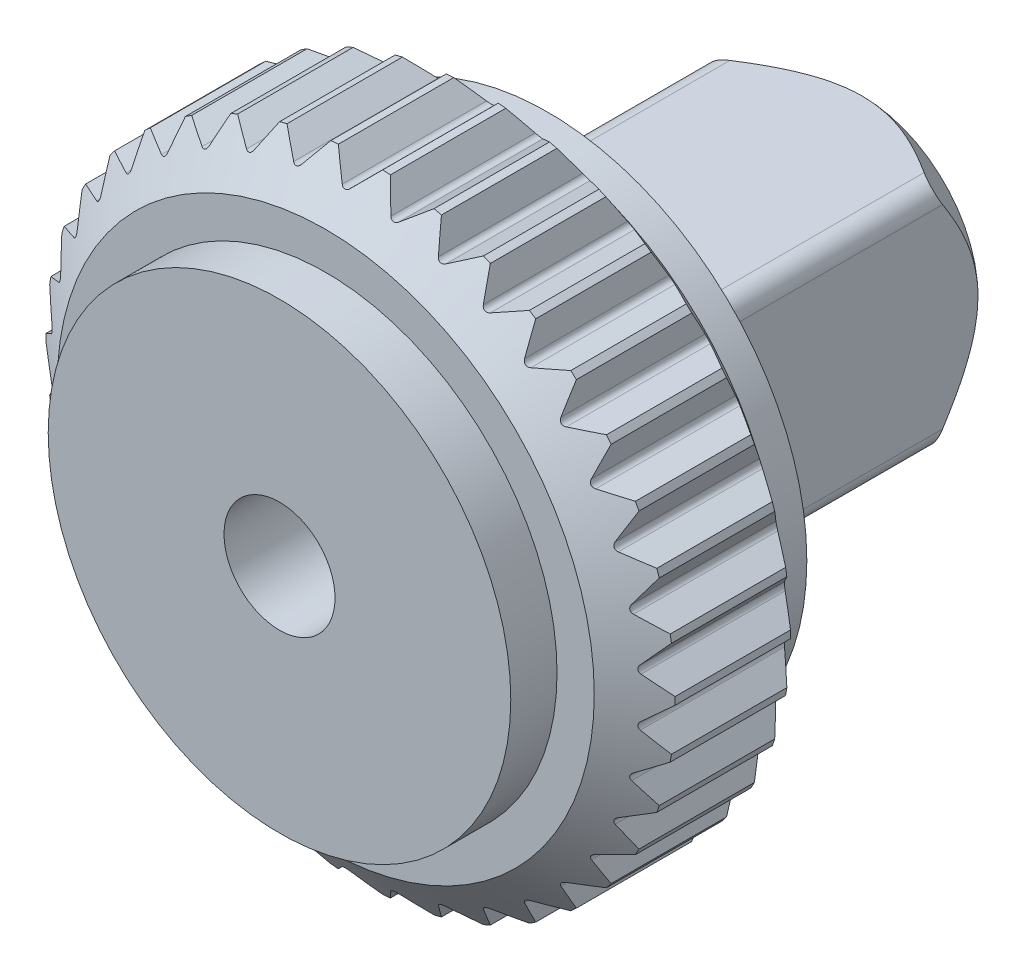
from build123d import *

# Parameters (mm, degrees)
DODANIE_WYCI_GNI_CIE1_DEPTH = 10
SZKIC3_R                    = 12.5
DODANIE_WYCI_GNI_CIE2_DEPTH = 2.5
SZKIC4_R                    = 14
DODANIE_WYCI_GNI_CIE3_DEPTH = 2
DODANIE_WYCI_GNI_CIE4_DEPTH = 17
ZAOKR_GLENIE1_R             = 1
SZKIC6_R                    = 3
WYTNIJ_WYCI_GNI_CIE1_DEPTH  = 32.5
SZKIC7_OUTSIDE_W            = 81.486
SZKIC7_OUTSIDE_H            = 81.402
SZKIC7_OUTSIDE_R            = 6.25
WYTNIJ_WYCI_GNI_CIE2_DEPTH  = 17
WYTNIJ_WYCI_GNI_CIE2_TAPER  = 45


with BuildPart() as part:
    # Szkic1 → Dodanie-wyciągnięcie1 (new body)
    with BuildSketch(Plane.XY):
        with BuildLine():
            Line((0.212132034, 15.969726203), (1.2, 16.957594169))
            ThreePointArc((1.2, 16.957594169), (1.403848873, 16.941936381), (1.6074947, 16.923828195))
            Line((1.6074947, 16.923828195), (2.419291711, 15.786835738))
            ThreePointArc((2.419291711, 15.786835738), (2.61406795, 15.665250392), (2.837769371, 15.717004168))
            Line((2.837769371, 15.717004168), (3.974761828, 16.528801179))
            ThreePointArc((3.974761828, 16.528801179), (4.173253281, 16.479804521), (4.371141136, 16.428424306))
            Line((4.371141136, 16.428424306), (4.984723486, 15.173321547))
            ThreePointArc((4.984723486, 15.173321547), (5.15683094, 15.021335351), (5.385999757, 15.035563229))
            Line((5.385999757, 15.035563229), (6.641102516, 15.64914558))
            ThreePointArc((6.641102516, 15.64914558), (6.828822219, 15.568146553), (7.015554235, 15.484895827))
            Line((7.015554235, 15.484895827), (7.414184998, 14.145918699))
            ThreePointArc((7.414184998, 14.145918699), (7.558929025, 13.96767744), (7.78731411, 13.943991321))
            Line((7.78731411, 13.943991321), (9.126291238, 14.342622084))
            ThreePointArc((9.126291238, 14.342622084), (9.298118688, 14.23183013), (9.468601304, 14.118979756))
            Line((9.468601304, 14.118979756), (9.641406871, 12.732652063))
            ThreePointArc((9.641406871, 12.732652063), (9.754839231, 12.5330177), (9.976210834, 12.472063679))
            Line((9.976210834, 12.472063679), (11.362538526, 12.644869245))
            ThreePointArc((11.362538526, 12.644869245), (11.513786718, 12.507306481), (11.663369612, 12.367934723))
            Line((11.663369612, 12.367934723), (11.605636297, 10.972071871))
            ThreePointArc((11.605636297, 10.972071871), (11.684662851, 10.756489908), (11.892982532, 10.659930652))
            Line((11.892982532, 10.659930652), (13.288845384, 10.602197337))
            ThreePointArc((13.288845384, 10.602197337), (13.41538866, 10.441616116), (13.539991601, 10.279524671))
            Line((13.539991601, 10.279524671), (13.253294219, 8.912202161))
            ThreePointArc((13.253294219, 8.912202161), (13.295759329, 8.686553111), (13.48534467, 8.557022505))
            Line((13.48534467, 8.557022505), (14.85266718, 8.270325123))
            ThreePointArc((14.85266718, 8.270325123), (14.951053771, 8.091105682), (15.047277915, 7.910715983))
            Line((15.047277915, 7.910715983), (14.539436823, 6.609230808))
            ThreePointArc((14.539436823, 6.609230808), (14.544182152, 6.379669789), (14.709861759, 6.22070109))
            Line((14.709861759, 6.22070109), (16.011346934, 5.712859999))
            ThreePointArc((16.011346934, 5.712859999), (16.078893109, 5.519890976), (16.144113713, 5.326123584))
            Line((16.144113713, 5.326123584), (15.428981493, 4.125976867))
            ThreePointArc((15.428981493, 4.125976867), (15.395877599, 3.898765706), (15.533132164, 3.714695166))
            Line((15.533132164, 3.714695166), (16.733278882, 2.999562946))
            ThreePointArc((16.733278882, 2.999562946), (16.768142158, 2.798108035), (16.800580173, 2.596248419))
            Line((16.800580173, 2.596248419), (15.897663767, 1.530177033))
            ThreePointArc((15.897663767, 1.530177033), (15.82761364, 1.311513458), (15.932699216, 1.107362041))
            Line((15.932699216, 1.107362041), (16.998770602, 0.204445636))
            ThreePointArc((16.998770602, 0.204445636), (17, 0), (16.998770602, -0.204445636))
            Line((16.998770602, -0.204445636), (15.932699216, -1.107362041))
            ThreePointArc((15.932699216, -1.107362041), (15.82761364, -1.311513458), (15.897663767, -1.530177033))
            Line((15.897663767, -1.530177033), (16.800580173, -2.596248419))
            ThreePointArc((16.800580173, -2.596248419), (16.768142158, -2.798108035), (16.733278882, -2.999562946))
            Line((16.733278882, -2.999562946), (15.533132164, -3.714695166))
            ThreePointArc((15.533132164, -3.714695166), (15.395877599, -3.898765706), (15.428981493, -4.125976867))
            Line((15.428981493, -4.125976867), (16.144113713, -5.326123584))
            ThreePointArc((16.144113713, -5.326123584), (16.078893109, -5.519890976), (16.011346934, -5.712859999))
            Line((16.011346934, -5.712859999), (14.709861759, -6.22070109))
            ThreePointArc((14.709861759, -6.22070109), (14.544182152, -6.379669789), (14.539436823, -6.609230808))
            Line((14.539436823, -6.609230808), (15.047277915, -7.910715983))
            ThreePointArc((15.047277915, -7.910715983), (14.951053771, -8.091105682), (14.85266718, -8.270325123))
            Line((14.85266718, -8.270325123), (13.48534467, -8.557022505))
            ThreePointArc((13.48534467, -8.557022505), (13.295759329, -8.686553111), (13.253294219, -8.912202161))
            Line((13.253294219, -8.912202161), (13.539991601, -10.279524671))
            ThreePointArc((13.539991601, -10.279524671), (13.41538866, -10.441616116), (13.288845384, -10.602197337))
            Line((13.288845384, -10.602197337), (11.892982532, -10.659930652))
            ThreePointArc((11.892982532, -10.659930652), (11.684662851, -10.756489908), (11.605636297, -10.972071871))
            Line((11.605636297, -10.972071871), (11.663369612, -12.367934723))
            ThreePointArc((11.663369612, -12.367934723), (11.513786718, -12.507306481), (11.362538526, -12.644869245))
            Line((11.362538526, -12.644869245), (9.976210834, -12.472063679))
            ThreePointArc((9.976210834, -12.472063679), (9.754839231, -12.5330177), (9.641406871, -12.732652063))
            Line((9.641406871, -12.732652063), (9.468601304, -14.118979756))
            ThreePointArc((9.468601304, -14.118979756), (9.298118688, -14.23183013), (9.126291238, -14.342622084))
            Line((9.126291238, -14.342622084), (7.78731411, -13.943991321))
            ThreePointArc((7.78731411, -13.943991321), (7.558929025, -13.96767744), (7.414184998, -14.145918699))
            Line((7.414184998, -14.145918699), (7.015554235, -15.484895827))
            ThreePointArc((7.015554235, -15.484895827), (6.828822219, -15.568146553), (6.641102516, -15.64914558))
            Line((6.641102516, -15.64914558), (5.385999757, -15.035563229))
            ThreePointArc((5.385999757, -15.035563229), (5.15683094, -15.021335351), (4.984723486, -15.173321547))
            Line((4.984723486, -15.173321547), (4.371141136, -16.428424306))
            ThreePointArc((4.371141136, -16.428424306), (4.173253281, -16.479804521), (3.974761828, -16.528801179))
            Line((3.974761828, -16.528801179), (2.837769371, -15.717004168))
            ThreePointArc((2.837769371, -15.717004168), (2.61406795, -15.665250392), (2.419291711, -15.786835738))
            Line((2.419291711, -15.786835738), (1.6074947, -16.923828195))
            ThreePointArc((1.6074947, -16.923828195), (1.403848873, -16.941936381), (1.2, -16.957594169))
            Line((1.2, -16.957594169), (0.212132034, -15.969726203))
            ThreePointArc((0.212132034, -15.969726203), (0, -15.881858238), (-0.212132034, -15.969726203))
            Line((-0.212132034, -15.969726203), (-1.2, -16.957594169))
            ThreePointArc((-1.2, -16.957594169), (-1.403848873, -16.941936381), (-1.6074947, -16.923828195))
            Line((-1.6074947, -16.923828195), (-2.419291711, -15.786835738))
            ThreePointArc((-2.419291711, -15.786835738), (-2.61406795, -15.665250392), (-2.837769371, -15.717004168))
            Line((-2.837769371, -15.717004168), (-3.974761828, -16.528801179))
            ThreePointArc((-3.974761828, -16.528801179), (-4.173253281, -16.479804521), (-4.371141136, -16.428424306))
            Line((-4.371141136, -16.428424306), (-4.984723486, -15.173321547))
            ThreePointArc((-4.984723486, -15.173321547), (-5.15683094, -15.021335351), (-5.385999757, -15.035563229))
            Line((-5.385999757, -15.035563229), (-6.641102516, -15.64914558))
            ThreePointArc((-6.641102516, -15.64914558), (-6.828822219, -15.568146553), (-7.015554235, -15.484895827))
            Line((-7.015554235, -15.484895827), (-7.414184998, -14.145918699))
            ThreePointArc((-7.414184998, -14.145918699), (-7.558929025, -13.96767744), (-7.78731411, -13.943991321))
            Line((-7.78731411, -13.943991321), (-9.126291238, -14.342622084))
            ThreePointArc((-9.126291238, -14.342622084), (-9.298118688, -14.23183013), (-9.468601304, -14.118979756))
            Line((-9.468601304, -14.118979756), (-9.641406871, -12.732652063))
            ThreePointArc((-9.641406871, -12.732652063), (-9.754839231, -12.5330177), (-9.976210834, -12.472063679))
            Line((-9.976210834, -12.472063679), (-11.362538526, -12.644869245))
            ThreePointArc((-11.362538526, -12.644869245), (-11.513786718, -12.507306481), (-11.663369612, -12.367934723))
            Line((-11.663369612, -12.367934723), (-11.605636297, -10.972071871))
            ThreePointArc((-11.605636297, -10.972071871), (-11.684662851, -10.756489908), (-11.892982532, -10.659930652))
            Line((-11.892982532, -10.659930652), (-13.288845384, -10.602197337))
            ThreePointArc((-13.288845384, -10.602197337), (-13.41538866, -10.441616116), (-13.539991601, -10.279524671))
            Line((-13.539991601, -10.279524671), (-13.253294219, -8.912202161))
            ThreePointArc((-13.253294219, -8.912202161), (-13.295759329, -8.686553111), (-13.48534467, -8.557022505))
            Line((-13.48534467, -8.557022505), (-14.85266718, -8.270325123))
            ThreePointArc((-14.85266718, -8.270325123), (-14.951053771, -8.091105682), (-15.047277915, -7.910715983))
            Line((-15.047277915, -7.910715983), (-14.539436823, -6.609230808))
            ThreePointArc((-14.539436823, -6.609230808), (-14.544182152, -6.379669789), (-14.709861759, -6.22070109))
            Line((-14.709861759, -6.22070109), (-16.011346934, -5.712859999))
            ThreePointArc((-16.011346934, -5.712859999), (-16.078893109, -5.519890976), (-16.144113713, -5.326123584))
            Line((-16.144113713, -5.326123584), (-15.428981493, -4.125976867))
            ThreePointArc((-15.428981493, -4.125976867), (-15.395877599, -3.898765706), (-15.533132164, -3.714695166))
            Line((-15.533132164, -3.714695166), (-16.733278882, -2.999562946))
            ThreePointArc((-16.733278882, -2.999562946), (-16.768142158, -2.798108035), (-16.800580173, -2.596248419))
            Line((-16.800580173, -2.596248419), (-15.897663767, -1.530177033))
            ThreePointArc((-15.897663767, -1.530177033), (-15.82761364, -1.311513458), (-15.932699216, -1.107362041))
            Line((-15.932699216, -1.107362041), (-16.998770602, -0.204445636))
            ThreePointArc((-16.998770602, -0.204445636), (-17, 0), (-16.998770602, 0.204445636))
            Line((-16.998770602, 0.204445636), (-15.932699216, 1.107362041))
            ThreePointArc((-15.932699216, 1.107362041), (-15.82761364, 1.311513458), (-15.897663767, 1.530177033))
            Line((-15.897663767, 1.530177033), (-16.800580173, 2.596248419))
            ThreePointArc((-16.800580173, 2.596248419), (-16.768142158, 2.798108035), (-16.733278882, 2.999562946))
            Line((-16.733278882, 2.999562946), (-15.533132164, 3.714695166))
            ThreePointArc((-15.533132164, 3.714695166), (-15.395877599, 3.898765706), (-15.428981493, 4.125976867))
            Line((-15.428981493, 4.125976867), (-16.144113713, 5.326123584))
            ThreePointArc((-16.144113713, 5.326123584), (-16.078893109, 5.519890976), (-16.011346934, 5.712859999))
            Line((-16.011346934, 5.712859999), (-14.709861759, 6.22070109))
            ThreePointArc((-14.709861759, 6.22070109), (-14.544182152, 6.379669789), (-14.539436823, 6.609230808))
            Line((-14.539436823, 6.609230808), (-15.047277915, 7.910715983))
            ThreePointArc((-15.047277915, 7.910715983), (-14.951053771, 8.091105682), (-14.85266718, 8.270325123))
            Line((-14.85266718, 8.270325123), (-13.48534467, 8.557022505))
            ThreePointArc((-13.48534467, 8.557022505), (-13.295759329, 8.686553111), (-13.253294219, 8.912202161))
            Line((-13.253294219, 8.912202161), (-13.539991601, 10.279524671))
            ThreePointArc((-13.539991601, 10.279524671), (-13.41538866, 10.441616116), (-13.288845384, 10.602197337))
            Line((-13.288845384, 10.602197337), (-11.892982532, 10.659930652))
            ThreePointArc((-11.892982532, 10.659930652), (-11.684662851, 10.756489908), (-11.605636297, 10.972071871))
            Line((-11.605636297, 10.972071871), (-11.663369612, 12.367934723))
            ThreePointArc((-11.663369612, 12.367934723), (-11.513786718, 12.507306481), (-11.362538526, 12.644869245))
            Line((-11.362538526, 12.644869245), (-9.976210834, 12.472063679))
            ThreePointArc((-9.976210834, 12.472063679), (-9.754839231, 12.5330177), (-9.641406871, 12.732652063))
            Line((-9.641406871, 12.732652063), (-9.468601304, 14.118979756))
            ThreePointArc((-9.468601304, 14.118979756), (-9.298118688, 14.23183013), (-9.126291238, 14.342622084))
            Line((-9.126291238, 14.342622084), (-7.78731411, 13.943991321))
            ThreePointArc((-7.78731411, 13.943991321), (-7.558929025, 13.96767744), (-7.414184998, 14.145918699))
            Line((-7.414184998, 14.145918699), (-7.015554235, 15.484895827))
            ThreePointArc((-7.015554235, 15.484895827), (-6.828822219, 15.568146553), (-6.641102516, 15.64914558))
            Line((-6.641102516, 15.64914558), (-5.385999757, 15.035563229))
            ThreePointArc((-5.385999757, 15.035563229), (-5.15683094, 15.021335351), (-4.984723486, 15.173321547))
            Line((-4.984723486, 15.173321547), (-4.371141136, 16.428424306))
            ThreePointArc((-4.371141136, 16.428424306), (-4.173253281, 16.479804521), (-3.974761828, 16.528801179))
            Line((-3.974761828, 16.528801179), (-2.837769371, 15.717004168))
            ThreePointArc((-2.837769371, 15.717004168), (-2.61406795, 15.665250392), (-2.419291711, 15.786835738))
            Line((-2.419291711, 15.786835738), (-1.6074947, 16.923828195))
            ThreePointArc((-1.6074947, 16.923828195), (-1.403848873, 16.941936381), (-1.2, 16.957594169))
            Line((-1.2, 16.957594169), (-0.212132034, 15.969726203))
            ThreePointArc((-0.212132034, 15.969726203), (0, 15.881858238), (0.212132034, 15.969726203))
        make_face()
    extrude(amount=DODANIE_WYCI_GNI_CIE1_DEPTH)

    # Szkic2 → Wycięcie-obrót1 (revolve, cut)
    with BuildSketch(Plane(origin=(0, 0, 0), x_dir=(0, 0, -1), z_dir=(1, 0, 0))):
        Polygon((-10, 14.511390723), (-10, 17.157594169), (-8, 17.157594169), align=None)
        Polygon((-2, 17.157594169), (0, 14.511390723), (0, 17.157594169), align=None)
    revolve(axis=Axis((0, 0, 10), (0, 0, -1)), mode=Mode.SUBTRACT)

    # Szkic3 → Dodanie-wyciągnięcie2 (add)
    with BuildSketch(Plane.XY.offset(10)):
        Circle(SZKIC3_R)
    extrude(amount=DODANIE_WYCI_GNI_CIE2_DEPTH)

    # Szkic4 → Dodanie-wyciągnięcie3 (add)
    with BuildSketch(Plane(origin=(0, 0, 0), x_dir=(-1, 0, 0), z_dir=(0, 0, -1))):
        Circle(SZKIC4_R)
    extrude(amount=DODANIE_WYCI_GNI_CIE3_DEPTH)

    # Szkic5 → Dodanie-wyciągnięcie4 (add)
    with BuildSketch(Plane(origin=(0, 0, -2), x_dir=(-1, 0, 0), z_dir=(0, 0, -1))):
        with BuildLine():
            Line((-5.25, -6.25), (5.25, -6.25))
            ThreePointArc((5.25, -6.25), (5.957106781, -5.957106781), (6.25, -5.25))
            Line((6.25, -5.25), (6.25, 5.25))
            ThreePointArc((6.25, 5.25), (5.957106781, 5.957106781), (5.25, 6.25))
            Line((5.25, 6.25), (-5.25, 6.25))
            ThreePointArc((-5.25, 6.25), (-5.957106781, 5.957106781), (-6.25, 5.25))
            Line((-6.25, 5.25), (-6.25, -5.25))
            ThreePointArc((-6.25, -5.25), (-5.957106781, -5.957106781), (-5.25, -6.25))
        make_face()
    extrude(amount=DODANIE_WYCI_GNI_CIE4_DEPTH)

    # Zaokrąglenie1
    zaokr_glenie1_edges = [part.edges().sort_by_distance(p)[0] for p in [
        (-5.957106781, 5.957106781, -2),
        (0, 6.25, -2),
        (5.957106781, 5.957106781, -2),
        (6.25, 0, -2),
        (5.957106781, -5.957106781, -2),
        (0, -6.25, -2),
        (-5.957106781, -5.957106781, -2),
        (-6.25, 0, -2),
    ]]
    fillet(zaokr_glenie1_edges, radius=ZAOKR_GLENIE1_R)

    # Szkic6 → Wytnij-wyciągnięcie1 (cut, through all)
    with BuildSketch(Plane(origin=(0, 0, -19), x_dir=(-1, 0, 0), z_dir=(0, 0, -1))):
        Circle(SZKIC6_R)
    extrude(amount=-WYTNIJ_WYCI_GNI_CIE1_DEPTH, mode=Mode.SUBTRACT)

    # Szkic7 outside → Wytnij-wyciągnięcie2 (cut)
    with BuildSketch(Plane(origin=(0, 0, -19), x_dir=(-1, 0, 0), z_dir=(0, 0, -1))):
        Rectangle(SZKIC7_OUTSIDE_W, SZKIC7_OUTSIDE_H)
        Circle(SZKIC7_OUTSIDE_R, mode=Mode.SUBTRACT)
    extrude(amount=-WYTNIJ_WYCI_GNI_CIE2_DEPTH, taper=WYTNIJ_WYCI_GNI_CIE2_TAPER, mode=Mode.SUBTRACT)


solid = part.part
